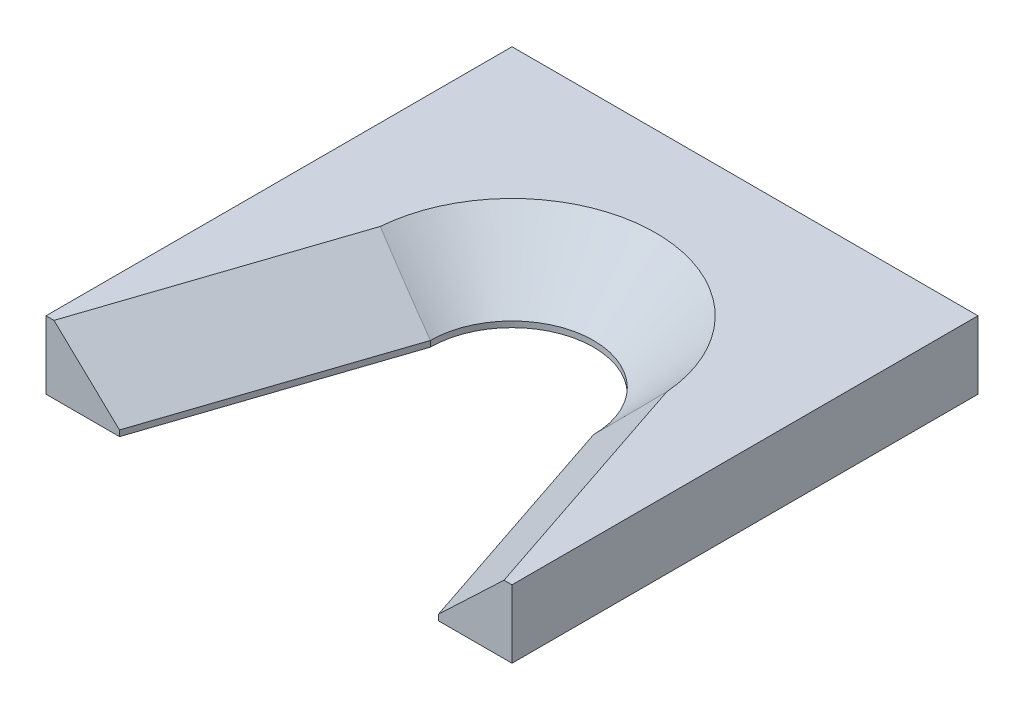
from build123d import *

# Parameters (mm, degrees)
BOSS_EXTRUDE1_DEPTH           = 11.1125
CHAMFER1_SIZE                 = 10.16
TAP_DRILL_FOR_8_32_TAP1_D     = 3.4544
TAP_DRILL_FOR_8_32_TAP1_DEPTH = 15.24
TAP_DRILL_FOR_8_32_TAP1_TIP   = 1.037806461


with BuildPart() as part:
    # Sketch1 → Boss-Extrude1 (new body)
    with BuildSketch(Plane(origin=(0, 0, 0), x_dir=(1, 0, 0), z_dir=(0, 1, 0))):
        with BuildLine():
            Line((-26.083081673, -38.1), (-13.335, 0))
            ThreePointArc((-13.335, 0), (0, 13.335), (13.335, 0))
            Line((13.335, 0), (26.083081673, -38.1))
            Line((26.083081673, -38.1), (38.1, -38.1))
            Line((38.1, -38.1), (38.1, 38.1))
            Line((38.1, 38.1), (-38.1, 38.1))
            Line((-38.1, 38.1), (-38.1, -38.1))
            Line((-38.1, -38.1), (-26.083081673, -38.1))
        make_face()
    extrude(amount=BOSS_EXTRUDE1_DEPTH)

    # Chamfer1
    chamfer1_edges = [part.edges().sort_by_distance(p)[0] for p in [
        (19.709040837, 11.1125, 19.05),
        (-19.709040837, 11.1125, 19.05),
        (0, 11.1125, -13.335),
    ]]
    chamfer(chamfer1_edges, length=CHAMFER1_SIZE)

    # Tap Drill for #8-32 Tap1
    with Locations(Plane(origin=(0, 5.55625, -38.1), x_dir=(-1, 0, 0), z_dir=(0, 0, -1))):
        with Locations((0, 0)):
            Hole(TAP_DRILL_FOR_8_32_TAP1_D / 2, depth=TAP_DRILL_FOR_8_32_TAP1_DEPTH)
            with Locations((0, 0, -(TAP_DRILL_FOR_8_32_TAP1_DEPTH + TAP_DRILL_FOR_8_32_TAP1_TIP / 2))):  # 118° drill point
                Cone(0, TAP_DRILL_FOR_8_32_TAP1_D / 2, TAP_DRILL_FOR_8_32_TAP1_TIP, mode=Mode.SUBTRACT)


solid = part.part
